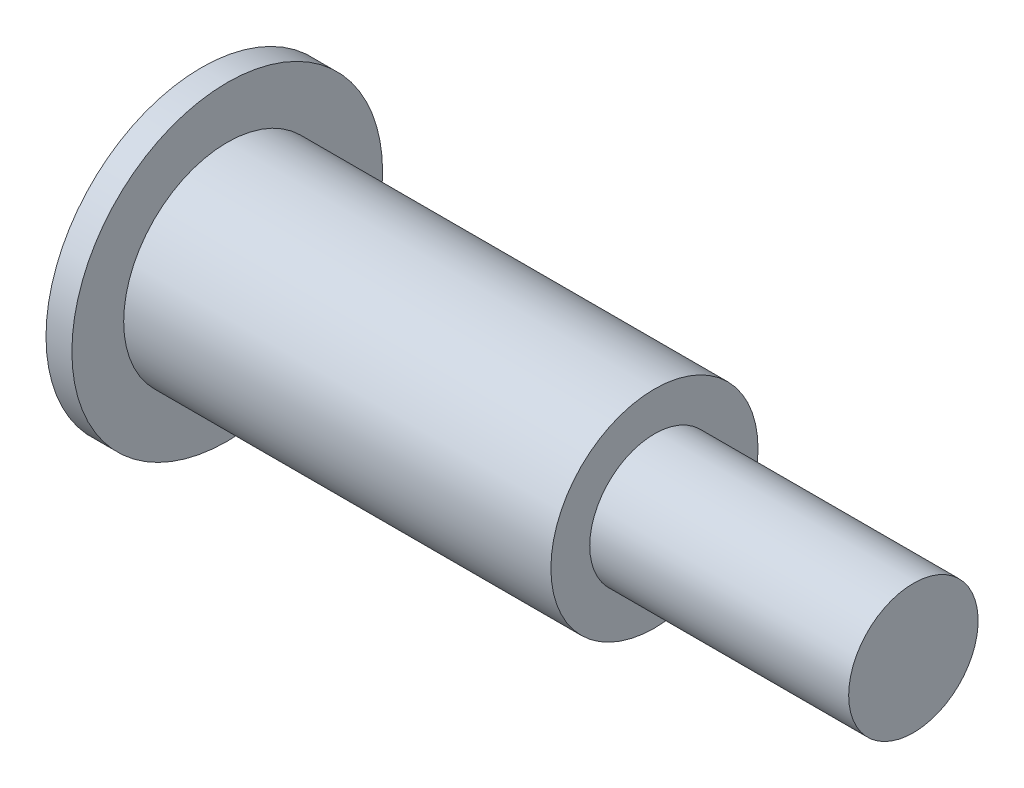
from build123d import *


with BuildPart() as part:
    # Esquisse1 → Révolution1 (revolve)
    with BuildSketch(Plane.XY):
        Polygon((0, 0), (0, 6), (1, 6), (1, 4), (17.5, 4), (17.5, 2.5), (27.5, 2.5), (27.5, 0), align=None)
    revolve(axis=Axis((0, 0, 0), (1, 0, 0)))


solid = part.part
